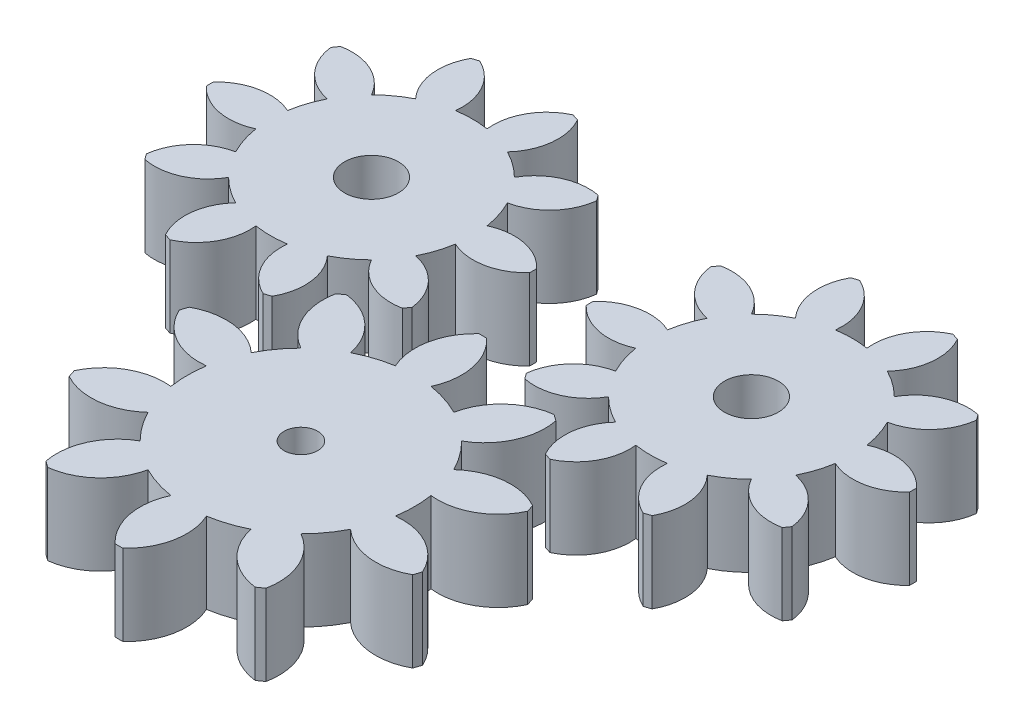
from build123d import *

# Parameters (mm, degrees)
SKETCH2_R             = 4
BOSS_EXTRUDE1_DEPTH   = 12
BOSS_EXTRUDE1_2_DEPTH = 12
SKETCH1_R             = 2.5
BOSS_EXTRUDE2_DEPTH   = 12


with BuildPart() as part:
    # Sketch2 → Boss-Extrude1 (new body)
    with BuildSketch(Plane(origin=(0, 0, 0), x_dir=(1, 0, 0), z_dir=(0, 1, 0))):
        with BuildLine():
            ThreePointArc((39.91929142, 68.654507651), (39.925113633, 69.183121198), (39.91929142, 69.711734744))
            ThreePointArc((39.91929142, 69.711734744), (35.623678248, 72.107813998), (30.738130346, 71.537805219))
            ThreePointArc((30.738130346, 71.537805219), (30.19001032, 73.818067096), (29.293144433, 75.985014574))
            ThreePointArc((29.293144433, 75.985014574), (33.580678467, 78.395520792), (35.647522476, 82.8588877))
            ThreePointArc((35.647522476, 82.8588877), (35.341521498, 83.289967253), (35.026099982, 83.714202385))
            ThreePointArc((35.026099982, 83.714202385), (30.142495876, 83.127773149), (26.52504735, 79.794973354))
            ThreePointArc((26.52504735, 79.794973354), (24.741304632, 81.317567096), (22.742025117, 82.54349989))
            ThreePointArc((22.742025117, 82.54349989), (24.793853009, 87.013789659), (23.842463693, 91.839589767))
            ThreePointArc((23.842463693, 91.839589767), (23.341521498, 92.008477589), (22.836980977, 92.166290906))
            ThreePointArc((22.836980977, 92.166290906), (19.230756718, 88.821349216), (18.263149953, 83.998774648))
            ThreePointArc((18.263149953, 83.998774648), (15.925113633, 84.182121198), (13.587077312, 83.998774648))
            ThreePointArc((13.587077312, 83.998774648), (12.619470547, 88.821349216), (9.013246288, 92.166290906))
            ThreePointArc((9.013246288, 92.166290906), (8.508705768, 92.008477589), (8.007763572, 91.839589767))
            ThreePointArc((8.007763572, 91.839589767), (7.056374256, 87.013789659), (9.108202148, 82.54349989))
            ThreePointArc((9.108202148, 82.54349989), (7.108922633, 81.317567097), (5.325179915, 79.794973354))
            ThreePointArc((5.325179915, 79.794973354), (1.707731389, 83.127773149), (-3.175872717, 83.714202385))
            ThreePointArc((-3.175872717, 83.714202385), (-3.491294233, 83.289967253), (-3.797295211, 82.8588877))
            ThreePointArc((-3.797295211, 82.8588877), (-1.730451202, 78.395520792), (2.557082832, 75.985014575))
            ThreePointArc((2.557082832, 75.985014575), (1.660216945, 73.818067097), (1.112096919, 71.537805219))
            ThreePointArc((1.112096919, 71.537805219), (-3.773450983, 72.107813998), (-8.069064155, 69.711734744))
            ThreePointArc((-8.069064155, 69.711734744), (-8.074886368, 69.183121198), (-8.069064155, 68.654507651))
            ThreePointArc((-8.069064155, 68.654507651), (-3.773450983, 66.258428398), (1.112096919, 66.828437177))
            ThreePointArc((1.112096919, 66.828437177), (1.660216945, 64.548175299), (2.557082832, 62.381227821))
            ThreePointArc((2.557082832, 62.381227821), (-1.730451202, 59.970721604), (-3.797295211, 55.507354696))
            ThreePointArc((-3.797295211, 55.507354696), (-3.491294233, 55.076275143), (-3.175872717, 54.652040011))
            ThreePointArc((-3.175872717, 54.652040011), (1.707731389, 55.238469247), (5.325179915, 58.571269042))
            ThreePointArc((5.325179915, 58.571269042), (7.108922633, 57.048675299), (9.108202148, 55.822742505))
            ThreePointArc((9.108202148, 55.822742505), (7.056374256, 51.352452737), (8.007763572, 46.526652629))
            ThreePointArc((8.007763572, 46.526652629), (8.508705768, 46.357764807), (9.013246288, 46.19995149))
            ThreePointArc((9.013246288, 46.19995149), (12.619470547, 49.54489318), (13.587077312, 54.367467747))
            ThreePointArc((13.587077312, 54.367467747), (15.925113633, 54.184121198), (18.263149953, 54.367467747))
            ThreePointArc((18.263149953, 54.367467747), (19.230756718, 49.54489318), (22.836980977, 46.19995149))
            ThreePointArc((22.836980977, 46.19995149), (23.341521498, 46.357764807), (23.842463693, 46.526652629))
            ThreePointArc((23.842463693, 46.526652629), (24.793853009, 51.352452737), (22.742025117, 55.822742505))
            ThreePointArc((22.742025117, 55.822742505), (24.741304632, 57.048675299), (26.52504735, 58.571269042))
            ThreePointArc((26.52504735, 58.571269042), (30.142495876, 55.238469247), (35.026099982, 54.652040011))
            ThreePointArc((35.026099982, 54.652040011), (35.341521498, 55.076275143), (35.647522476, 55.507354696))
            ThreePointArc((35.647522476, 55.507354696), (33.580678467, 59.970721604), (29.293144433, 62.381227821))
            ThreePointArc((29.293144433, 62.381227821), (30.19001032, 64.548175299), (30.738130346, 66.828437177))
            ThreePointArc((30.738130346, 66.828437177), (35.623678248, 66.258428398), (39.91929142, 68.654507651))
        make_face()
        with Locations(Location((15.925113633, 69.183121198, 0), (0, 0, 270))):  # turned: the seam where the file's is
            Circle(SKETCH2_R, mode=Mode.SUBTRACT)
    extrude(amount=BOSS_EXTRUDE1_DEPTH)


with BuildPart() as body_2:
    # Sketch2 → Boss-Extrude1 2 (new body)
    with BuildSketch(Plane(origin=(0, 0, 0), x_dir=(1, 0, 0), z_dir=(0, 1, 0))):
        with BuildLine():
            ThreePointArc((96.30636676, 68.654507651), (96.312188972, 69.183121198), (96.30636676, 69.711734744))
            ThreePointArc((96.30636676, 69.711734744), (92.010753588, 72.107813998), (87.125205686, 71.537805219))
            ThreePointArc((87.125205686, 71.537805219), (86.57708566, 73.818067096), (85.680219773, 75.985014574))
            ThreePointArc((85.680219773, 75.985014574), (89.967753806, 78.395520792), (92.034597815, 82.8588877))
            ThreePointArc((92.034597815, 82.8588877), (91.728596837, 83.289967253), (91.413175321, 83.714202385))
            ThreePointArc((91.413175321, 83.714202385), (86.529571216, 83.127773149), (82.91212269, 79.794973354))
            ThreePointArc((82.91212269, 79.794973354), (81.128379971, 81.317567096), (79.129100457, 82.54349989))
            ThreePointArc((79.129100457, 82.54349989), (81.180928348, 87.013789659), (80.229539032, 91.839589767))
            ThreePointArc((80.229539032, 91.839589767), (79.728596837, 92.008477589), (79.224056316, 92.166290906))
            ThreePointArc((79.224056316, 92.166290906), (75.617832057, 88.821349216), (74.650225292, 83.998774648))
            ThreePointArc((74.650225292, 83.998774648), (72.312188972, 84.182121198), (69.974152652, 83.998774648))
            ThreePointArc((69.974152652, 83.998774648), (69.006545886, 88.821349216), (65.400321627, 92.166290906))
            ThreePointArc((65.400321627, 92.166290906), (64.895781107, 92.008477589), (64.394838911, 91.839589767))
            ThreePointArc((64.394838911, 91.839589767), (63.443449595, 87.013789659), (65.495277487, 82.54349989))
            ThreePointArc((65.495277487, 82.54349989), (63.495997973, 81.317567097), (61.712255254, 79.794973354))
            ThreePointArc((61.712255254, 79.794973354), (58.094806728, 83.127773149), (53.211202622, 83.714202385))
            ThreePointArc((53.211202622, 83.714202385), (52.895781107, 83.289967253), (52.589780128, 82.8588877))
            ThreePointArc((52.589780128, 82.8588877), (54.656624137, 78.395520792), (58.944158171, 75.985014575))
            ThreePointArc((58.944158171, 75.985014575), (58.047292284, 73.818067097), (57.499172258, 71.537805219))
            ThreePointArc((57.499172258, 71.537805219), (52.613624356, 72.107813998), (48.318011184, 69.711734744))
            ThreePointArc((48.318011184, 69.711734744), (48.312188972, 69.183121198), (48.318011184, 68.654507651))
            ThreePointArc((48.318011184, 68.654507651), (52.613624356, 66.258428398), (57.499172258, 66.828437177))
            ThreePointArc((57.499172258, 66.828437177), (58.047292284, 64.548175299), (58.944158171, 62.381227821))
            ThreePointArc((58.944158171, 62.381227821), (54.656624137, 59.970721604), (52.589780128, 55.507354696))
            ThreePointArc((52.589780128, 55.507354696), (52.895781107, 55.076275143), (53.211202622, 54.652040011))
            ThreePointArc((53.211202622, 54.652040011), (58.094806728, 55.238469247), (61.712255254, 58.571269042))
            ThreePointArc((61.712255254, 58.571269042), (63.495997973, 57.048675299), (65.495277487, 55.822742505))
            ThreePointArc((65.495277487, 55.822742505), (63.443449595, 51.352452737), (64.394838911, 46.526652629))
            ThreePointArc((64.394838911, 46.526652629), (64.895781107, 46.357764807), (65.400321627, 46.19995149))
            ThreePointArc((65.400321627, 46.19995149), (69.006545886, 49.54489318), (69.974152652, 54.367467747))
            ThreePointArc((69.974152652, 54.367467747), (72.312188972, 54.184121198), (74.650225292, 54.367467747))
            ThreePointArc((74.650225292, 54.367467747), (75.617832058, 49.54489318), (79.224056316, 46.19995149))
            ThreePointArc((79.224056316, 46.19995149), (79.728596837, 46.357764807), (80.229539032, 46.526652629))
            ThreePointArc((80.229539032, 46.526652629), (81.180928348, 51.352452737), (79.129100457, 55.822742505))
            ThreePointArc((79.129100457, 55.822742505), (81.128379971, 57.048675299), (82.91212269, 58.571269042))
            ThreePointArc((82.91212269, 58.571269042), (86.529571216, 55.238469247), (91.413175322, 54.652040011))
            ThreePointArc((91.413175322, 54.652040011), (91.728596837, 55.076275143), (92.034597815, 55.507354696))
            ThreePointArc((92.034597815, 55.507354696), (89.967753806, 59.970721604), (85.680219773, 62.381227821))
            ThreePointArc((85.680219773, 62.381227821), (86.57708566, 64.548175299), (87.125205686, 66.828437177))
            ThreePointArc((87.125205686, 66.828437177), (92.010753588, 66.258428398), (96.30636676, 68.654507651))
        make_face()
        with Locations(Location((72.312188972, 69.183121198, 0), (0, 0, 270))):  # turned: the seam where the file's is
            Circle(SKETCH2_R, mode=Mode.SUBTRACT)
    extrude(amount=BOSS_EXTRUDE1_2_DEPTH)


with BuildPart() as body_3:
    # Sketch1 → Boss-Extrude2 (new body)
    with BuildSketch(Plane(origin=(0, 0, 0), x_dir=(1, 0, 0), z_dir=(0, 1, 0))):
        with BuildLine():
            ThreePointArc((45.159534103, 57.054132786), (44.573597006, 57.060491355), (43.987659909, 57.054132786))
            ThreePointArc((43.987659909, 57.054132786), (41.29051652, 52.222505932), (41.929927551, 46.72611129))
            ThreePointArc((41.929927551, 46.72611129), (39.359244243, 46.108619011), (36.916564905, 45.097171022))
            ThreePointArc((36.916564905, 45.097171022), (34.203159585, 49.919684069), (29.181165736, 52.243211197))
            ThreePointArc((29.181165736, 52.243211197), (28.703395194, 51.903950203), (28.233099598, 51.554400828))
            ThreePointArc((28.233099598, 51.554400828), (28.891023769, 46.060191485), (32.639017871, 41.989351186))
            ThreePointArc((32.639017871, 41.989351186), (30.922244243, 39.978779702), (29.540589358, 37.724730199))
            ThreePointArc((29.540589358, 37.724730199), (24.510796293, 40.031325579), (19.082182945, 38.959244591))
            ThreePointArc((19.082182945, 38.959244591), (18.895071066, 38.403950203), (18.720053904, 37.844726003))
            ThreePointArc((18.720053904, 37.844726003), (22.481740965, 33.786535398), (27.90671178, 32.696172074))
            ThreePointArc((27.90671178, 32.696172074), (27.699597006, 30.060491355), (27.90671178, 27.424810636))
            ThreePointArc((27.90671178, 27.424810636), (22.481740964, 26.334447311), (18.720053904, 22.276256707))
            ThreePointArc((18.720053904, 22.276256707), (18.895071066, 21.717032507), (19.082182945, 21.161738118))
            ThreePointArc((19.082182945, 21.161738118), (24.510796293, 20.089657131), (29.540589358, 22.396252511))
            ThreePointArc((29.540589358, 22.396252511), (30.922244243, 20.142203008), (32.639017871, 18.131631524))
            ThreePointArc((32.639017871, 18.131631524), (28.891023769, 14.060791225), (28.233099598, 8.566581881))
            ThreePointArc((28.233099598, 8.566581881), (28.703395194, 8.217032507), (29.181165736, 7.877771512))
            ThreePointArc((29.181165736, 7.877771512), (34.203159585, 10.20129864), (36.916564905, 15.023811688))
            ThreePointArc((36.916564905, 15.023811688), (39.359244243, 14.012363699), (41.929927551, 13.39487142))
            ThreePointArc((41.929927551, 13.39487142), (41.29051652, 7.898476778), (43.987659909, 3.066849924))
            ThreePointArc((43.987659909, 3.066849924), (44.573597006, 3.060491355), (45.159534103, 3.066849924))
            ThreePointArc((45.159534103, 3.066849924), (47.856677493, 7.898476778), (47.217266462, 13.39487142))
            ThreePointArc((47.217266462, 13.39487142), (49.787949769, 14.012363699), (52.230629107, 15.023811688))
            ThreePointArc((52.230629107, 15.023811688), (54.944034428, 10.201298641), (59.966028276, 7.877771513))
            ThreePointArc((59.966028276, 7.877771513), (60.443798818, 8.217032507), (60.914094414, 8.566581881))
            ThreePointArc((60.914094414, 8.566581881), (60.256170243, 14.060791225), (56.508176141, 18.131631524))
            ThreePointArc((56.508176141, 18.131631524), (58.224949769, 20.142203008), (59.606604654, 22.396252511))
            ThreePointArc((59.606604654, 22.396252511), (64.636397719, 20.089657131), (70.065011067, 21.161738118))
            ThreePointArc((70.065011067, 21.161738118), (70.252122946, 21.717032507), (70.427140109, 22.276256707))
            ThreePointArc((70.427140109, 22.276256707), (66.665453048, 26.334447311), (61.240482233, 27.424810636))
            ThreePointArc((61.240482233, 27.424810636), (61.447597006, 30.060491355), (61.240482233, 32.696172074))
            ThreePointArc((61.240482233, 32.696172074), (66.665453048, 33.786535398), (70.427140109, 37.844726003))
            ThreePointArc((70.427140109, 37.844726003), (70.252122946, 38.403950203), (70.065011067, 38.959244591))
            ThreePointArc((70.065011067, 38.959244591), (64.636397719, 40.031325579), (59.606604654, 37.724730199))
            ThreePointArc((59.606604654, 37.724730199), (58.224949769, 39.978779702), (56.508176141, 41.989351186))
            ThreePointArc((56.508176141, 41.989351186), (60.256170243, 46.060191485), (60.914094414, 51.554400828))
            ThreePointArc((60.914094414, 51.554400828), (60.443798818, 51.903950203), (59.966028276, 52.243211197))
            ThreePointArc((59.966028276, 52.243211197), (54.944034428, 49.919684069), (52.230629107, 45.097171022))
            ThreePointArc((52.230629107, 45.097171022), (49.787949769, 46.108619011), (47.217266462, 46.72611129))
            ThreePointArc((47.217266462, 46.72611129), (47.856677493, 52.222505932), (45.159534103, 57.054132786))
        make_face()
        with Locations(Location((44.573597006, 30.060491355, 0), (0, 0, 270))):  # turned: the seam where the file's is
            Circle(SKETCH1_R, mode=Mode.SUBTRACT)
    extrude(amount=BOSS_EXTRUDE2_DEPTH)


solid = Compound([part.part, body_2.part, body_3.part])
